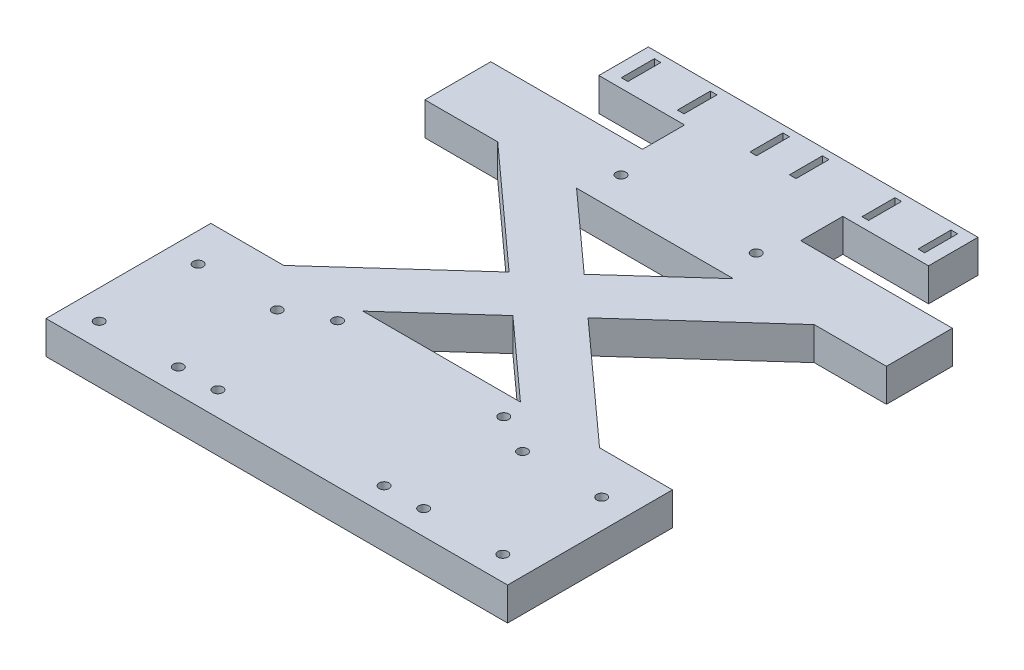
from build123d import *

# Parameters (mm, degrees)
SKETCH_1_R      = 1.5
SKETCH_1_W      = 2
SKETCH_1_H      = 10
EXTRUDE_1_DEPTH = 10


with BuildPart() as part:
    # 草图1 → 凸台-拉伸1 (new body)
    with BuildSketch(Plane(origin=(0, 0, 0), x_dir=(1, 0, 0), z_dir=(0, 1, 0))):
        Polygon((-68, 25), (-47.9, 25), (-11.972426803, 57.430508537), (-47.9, 89.910872233), (-68, 89.910872233), (-70, 89.910872233), (-70, 91.910872233), (-70, 107.910872233), (-70, 109.910872233), (-68, 109.910872233), (-24, 109.910872233), (-24, 114.855181995), (-24, 122.684078109), (-50, 122.684078109), (-50, 137.684078109), (50, 137.684078109), (50, 122.684078109), (24, 122.684078109), (24, 114.855181995), (24, 109.910872233), (68, 109.910872233), (70, 109.910872233), (70, 107.910872233), (70, 91.910872233), (70, 89.910872233), (68, 89.910872233), (48.1, 89.910872233), (12.022357286, 57.385438113), (47.9, 25), (68, 25), (70, 25), (70, 23), (70, -23), (70, -25), (68, -25), (-68, -25), (-70, -25), (-70, -23), (-70, 23), (-70, 25), align=None)
        with Locations((-61.207159892, 12.346732779)):
            Circle(SKETCH_1_R, mode=Mode.SUBTRACT)
        with Locations((-37.207159892, 12.346732779)):
            Circle(SKETCH_1_R, mode=Mode.SUBTRACT)
        with Locations((-37.207159892, -17.653267221)):
            Circle(SKETCH_1_R, mode=Mode.SUBTRACT)
        with Locations((-61.207159892, -17.653267221)):
            Circle(SKETCH_1_R, mode=Mode.SUBTRACT)
        with Locations((61.207159892, -17.653267221)):
            Circle(SKETCH_1_R, mode=Mode.SUBTRACT)
        with Locations((37.207159892, -17.653267221)):
            Circle(SKETCH_1_R, mode=Mode.SUBTRACT)
        with Locations((37.207159892, 12.346732779)):
            Circle(SKETCH_1_R, mode=Mode.SUBTRACT)
        with Locations((61.207159892, 12.346732779)):
            Circle(SKETCH_1_R, mode=Mode.SUBTRACT)
        with Locations((-20.5, 99.910872233)):
            Circle(SKETCH_1_R, mode=Mode.SUBTRACT)
        with Locations((20.5, 99.910872233)):
            Circle(SKETCH_1_R, mode=Mode.SUBTRACT)
        with Locations((-25.210114711, 18.628541516)):
            Circle(SKETCH_1_R, mode=Mode.SUBTRACT)
        with Locations((25.210114711, 18.628541516)):
            Circle(SKETCH_1_R, mode=Mode.SUBTRACT)
        with Locations((-25.210114711, -17.653267221)):
            Circle(SKETCH_1_R, mode=Mode.SUBTRACT)
        with Locations((25.210114711, -17.653267221)):
            Circle(SKETCH_1_R, mode=Mode.SUBTRACT)
        with Locations((6, 130.50199448)):
            Rectangle(SKETCH_1_W, SKETCH_1_H, mode=Mode.SUBTRACT)
        with Locations((-6, 130.50199448)):
            Rectangle(SKETCH_1_W, SKETCH_1_H, mode=Mode.SUBTRACT)
        with Locations((28, 130.50199448)):
            Rectangle(SKETCH_1_W, SKETCH_1_H, mode=Mode.SUBTRACT)
        with Locations((45, 130.50199448)):
            Rectangle(SKETCH_1_W, SKETCH_1_H, mode=Mode.SUBTRACT)
        with Locations((-45, 130.50199448)):
            Rectangle(SKETCH_1_W, SKETCH_1_H, mode=Mode.SUBTRACT)
        with Locations((-28, 130.50199448)):
            Rectangle(SKETCH_1_W, SKETCH_1_H, mode=Mode.SUBTRACT)
        Polygon((-23.789706762, 89.711680759), (23.789706762, 89.711680759), (0, 68.237581075), align=None, mode=Mode.SUBTRACT)
        Polygon((-23.9, 25), (0.033240612, 46.576771159), (23.9, 25), align=None, mode=Mode.SUBTRACT)
    extrude(amount=EXTRUDE_1_DEPTH)


solid = part.part
